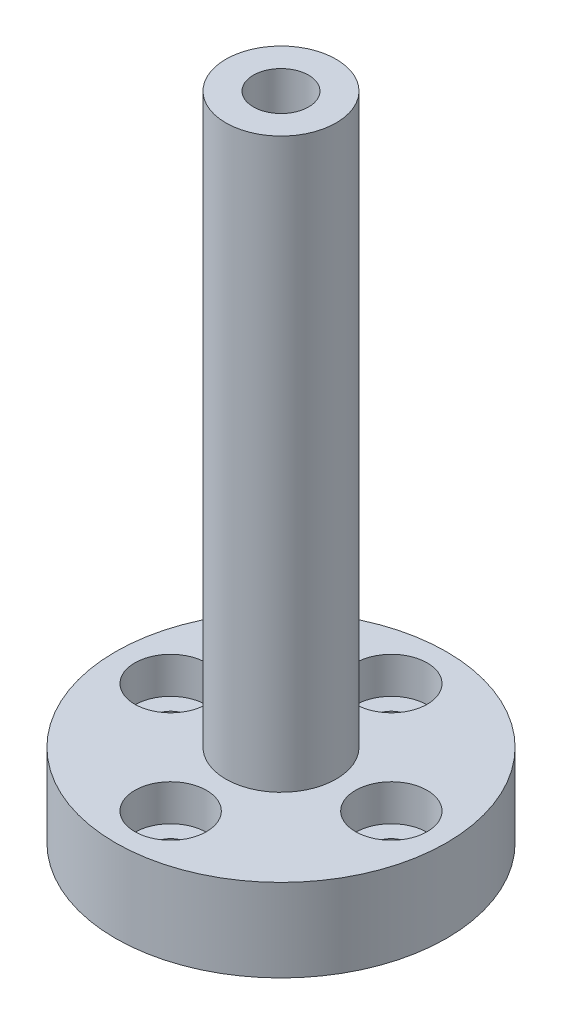
from build123d import *

# Parameters (mm, degrees)
SKETCH1_R           = 30
BOSS_EXTRUDE1_DEPTH = 15
SKETCH2_R           = 10
BOSS_EXTRUDE2_DEPTH = 103
SKETCH4_R           = 7.25
CUT_EXTRUDE1_DEPTH  = 57
SKETCH5_R           = 5
CUT_EXTRUDE2_DEPTH  = 62
SKETCH7_R           = 6.5
CUT_EXTRUDE3_DEPTH  = 6.6
SKETCH8_R           = 3.2
CUT_EXTRUDE4_DEPTH  = 9.4
CIRPATTERN1_COUNT   = 4


with BuildPart() as part:
    # Sketch1 → Boss-Extrude1 (new body)
    with BuildSketch(Plane(origin=(0, 0, 0), x_dir=(1, 0, 0), z_dir=(0, 1, 0))):
        Circle(SKETCH1_R)
    extrude(amount=BOSS_EXTRUDE1_DEPTH)

    # Sketch2 → Boss-Extrude2 (add)
    with BuildSketch(Plane(origin=(0, 15, 0), x_dir=(1, 0, 0), z_dir=(0, 1, 0))):
        Circle(SKETCH2_R)
    extrude(amount=BOSS_EXTRUDE2_DEPTH)

    # Sketch4 → Cut-Extrude1 (cut)
    with BuildSketch(Plane.XZ):
        Circle(SKETCH4_R)
    extrude(amount=-CUT_EXTRUDE1_DEPTH, mode=Mode.SUBTRACT)

    # Sketch5 → Cut-Extrude2 (cut, through all)
    with BuildSketch(Plane.XZ.offset(-57)):
        Circle(SKETCH5_R)
    extrude(amount=-CUT_EXTRUDE2_DEPTH, mode=Mode.SUBTRACT)

    # Sketch7 → Cut-Extrude3 (cut)
    with BuildSketch(Plane(origin=(0, 15, 0), x_dir=(1, 0, 0), z_dir=(0, 1, 0))):
        with Locations((0, -20)):
            Circle(SKETCH7_R)
    cut_extrude3 = extrude(amount=-CUT_EXTRUDE3_DEPTH, mode=Mode.SUBTRACT)

    # Sketch8 → Cut-Extrude4 (cut, through all)
    with BuildSketch(Plane(origin=(0, 8.4, 0), x_dir=(1, 0, 0), z_dir=(0, 1, 0))):
        with Locations((0, -20)):
            Circle(SKETCH8_R)
    cut_extrude4 = extrude(amount=-CUT_EXTRUDE4_DEPTH, mode=Mode.SUBTRACT)

    # CirPattern1: Cut-Extrude3, Cut-Extrude4 ×4 about axis
    cirpattern1_axis = Axis((0, 0, 0), (0, 1, 0))
    for i in range(1, CIRPATTERN1_COUNT):
        add(cut_extrude3.rotate(cirpattern1_axis, i * 360 / CIRPATTERN1_COUNT), mode=Mode.SUBTRACT)
        add(cut_extrude4.rotate(cirpattern1_axis, i * 360 / CIRPATTERN1_COUNT), mode=Mode.SUBTRACT)


solid = part.part
